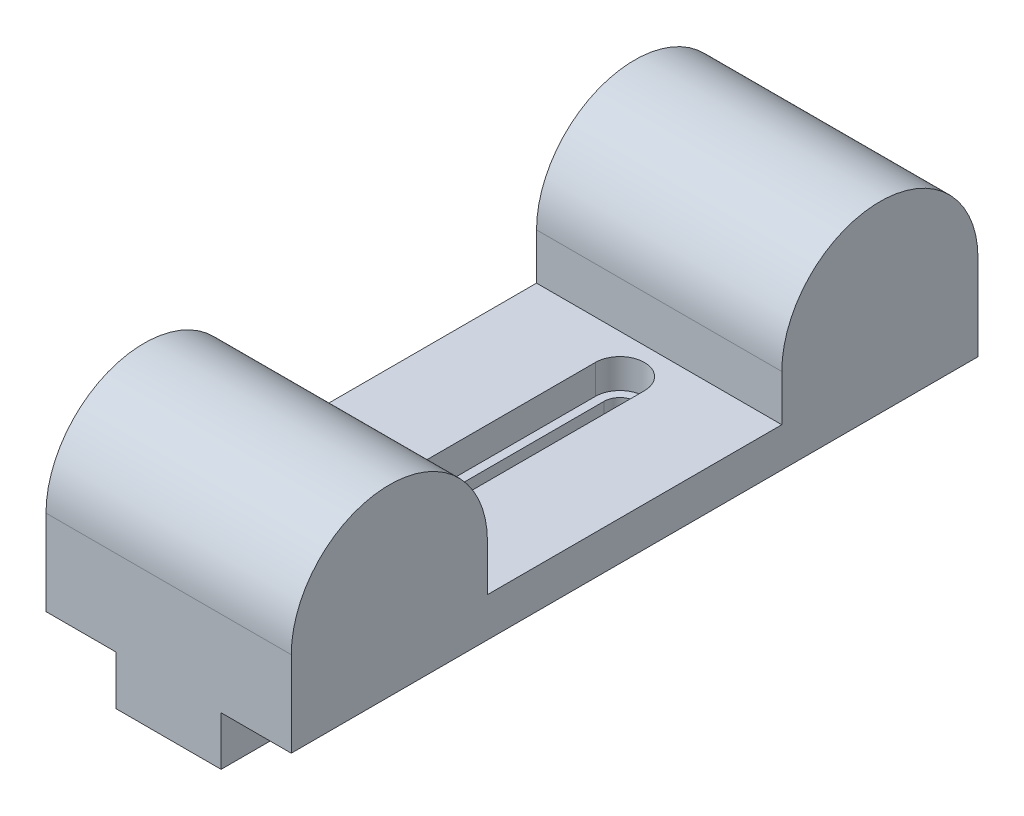
from build123d import *

# Parameters (mm, degrees)
BOSS_EXTRUDE1_DEPTH     = 12.5
SKETCH2_W               = 10.7
SKETCH2_H               = 41.65
BOSS_EXTRUDE2_DEPTH     = 5
CUT_EXTRUDE1_DEPTH      = 19.7
CUT_EXTRUDE1_DEPTH_BACK = 6
CUT_EXTRUDE2_START      = 4
CUT_EXTRUDE2_DEPTH      = 3


with BuildPart() as part:
    # Sketch1 → Boss-Extrude1 (new body, symmetric)
    with BuildSketch(Plane(origin=(0, 0, 0), x_dir=(0, 0, -1), z_dir=(1, 0, 0))):
        with BuildLine():
            Line((0, 0), (70, 0))
            Line((70, 0), (70, 8.7))
            ThreePointArc((70, 8.7), (60, 18.7), (50, 8.7))
            Line((50, 8.7), (50, 4))
            Line((50, 4), (20, 4))
            Line((20, 4), (20, 8.7))
            ThreePointArc((20, 8.7), (10, 18.7), (0, 8.7))
            Line((0, 8.7), (0, 0))
        make_face()
    extrude(amount=BOSS_EXTRUDE1_DEPTH, both=True)

    # Sketch2 → Boss-Extrude2 (add)
    with BuildSketch(Plane(origin=(0, 0, 0), x_dir=(1, 0, 0), z_dir=(0, 1, 0))):
        with BuildLine():
            ThreePointArc((-5.35, 41.65), (0, 47), (5.35, 41.65))
            Line((5.35, 41.65), (-5.35, 41.65))
        make_face()
        with Locations((0, 20.825)):
            Rectangle(SKETCH2_W, SKETCH2_H)
    extrude(amount=-BOSS_EXTRUDE2_DEPTH)

    # Sketch4 → Cut-Extrude1 (cut, two sides)
    with BuildSketch(Plane(origin=(0, 0, 0), x_dir=(1, 0, 0), z_dir=(0, 1, 0))) as cut_extrude1_sk:
        with BuildLine():
            Line((-1.625, 40), (1.625, 40))
            Line((1.625, 40), (1.625, 46))
            ThreePointArc((1.625, 46), (0, 47.625), (-1.625, 46))
            Line((-1.625, 46), (-1.625, 40))
        make_face()
        with BuildLine():
            Line((1.625, 38.100164481), (1.625, 40))
            ThreePointArc((1.625, 40), (0, 38.375), (-1.625, 40))
            Line((-1.625, 40), (-1.625, 38.100164481))
            ThreePointArc((-1.625, 38.100164481), (0, 37.5), (1.625, 38.100164481))
        make_face()
        with BuildLine():
            ThreePointArc((-1.625, 40), (0, 38.375), (1.625, 40))
            Line((1.625, 40), (-1.625, 40))
        make_face()
        with BuildLine():
            Line((1.625, 32.899835519), (1.625, 38.100164481))
            ThreePointArc((1.625, 38.100164481), (0, 37.5), (-1.625, 38.100164481))
            Line((-1.625, 38.100164481), (-1.625, 32.899835519))
            ThreePointArc((-1.625, 32.899835519), (0, 33.5), (1.625, 32.899835519))
        make_face()
        with BuildLine():
            ThreePointArc((-1.625, 31), (0, 32.625), (1.625, 31))
            Line((1.625, 31), (1.625, 32.899835519))
            ThreePointArc((1.625, 32.899835519), (0, 33.5), (-1.625, 32.899835519))
            Line((-1.625, 32.899835519), (-1.625, 31))
        make_face()
        with BuildLine():
            Line((-1.625, 31), (1.625, 31))
            ThreePointArc((1.625, 31), (0, 32.625), (-1.625, 31))
        make_face()
        with BuildLine():
            Line((1.625, 25), (1.625, 31))
            Line((1.625, 31), (-1.625, 31))
            Line((-1.625, 31), (-1.625, 25))
            ThreePointArc((-1.625, 25), (0, 23.375), (1.625, 25))
        make_face()
    extrude(amount=CUT_EXTRUDE1_DEPTH, mode=Mode.SUBTRACT)
    extrude(cut_extrude1_sk.sketch, amount=-CUT_EXTRUDE1_DEPTH_BACK, mode=Mode.SUBTRACT)

    # Sketch4_3 → Cut-Extrude2 (cut)
    with BuildSketch(Plane(origin=(0, 0, 0), x_dir=(1, 0, 0), z_dir=(0, 1, 0)).offset(CUT_EXTRUDE2_START)):
        with BuildLine():
            Line((2.5, 25), (2.5, 31))
            Line((2.5, 31), (1.625, 31))
            Line((1.625, 31), (1.625, 25))
            ThreePointArc((1.625, 25), (0, 23.375), (-1.625, 25))
            Line((-1.625, 25), (-1.625, 31))
            Line((-1.625, 31), (-2.5, 31))
            Line((-2.5, 31), (-2.5, 25))
            ThreePointArc((-2.5, 25), (0, 22.5), (2.5, 25))
        make_face()
        with BuildLine():
            ThreePointArc((-1.625, 32.899835519), (-2.270737766, 32.045825033), (-2.5, 31))
            Line((-2.5, 31), (-1.625, 31))
            Line((-1.625, 31), (-1.625, 32.899835519))
        make_face()
        with BuildLine():
            ThreePointArc((-1.625, 38.100164481), (-2.270737766, 38.954174967), (-2.5, 40))
            Line((-2.5, 40), (-2.5, 31))
            ThreePointArc((-2.5, 31), (-2.270737766, 32.045825033), (-1.625, 32.899835519))
            Line((-1.625, 32.899835519), (-1.625, 38.100164481))
        make_face()
        with BuildLine():
            Line((1.625, 31), (2.5, 31))
            ThreePointArc((2.5, 31), (2.270737766, 32.045825033), (1.625, 32.899835519))
            Line((1.625, 32.899835519), (1.625, 31))
        make_face()
        with BuildLine():
            Line((2.5, 31), (2.5, 40))
            ThreePointArc((2.5, 40), (2.270737766, 38.954174967), (1.625, 38.100164481))
            Line((1.625, 38.100164481), (1.625, 32.899835519))
            ThreePointArc((1.625, 32.899835519), (2.270737766, 32.045825033), (2.5, 31))
        make_face()
        with BuildLine():
            ThreePointArc((1.625, 38.100164481), (2.270737766, 38.954174967), (2.5, 40))
            Line((2.5, 40), (1.625, 40))
            Line((1.625, 40), (1.625, 38.100164481))
        make_face()
        with BuildLine():
            Line((2.5, 40), (2.5, 46))
            ThreePointArc((2.5, 46), (0, 48.5), (-2.5, 46))
            Line((-2.5, 46), (-2.5, 40))
            Line((-2.5, 40), (-1.625, 40))
            Line((-1.625, 40), (-1.625, 46))
            ThreePointArc((-1.625, 46), (0, 47.625), (1.625, 46))
            Line((1.625, 46), (1.625, 40))
            Line((1.625, 40), (2.5, 40))
        make_face()
        with BuildLine():
            Line((-1.625, 40), (-2.5, 40))
            ThreePointArc((-2.5, 40), (-2.270737766, 38.954174967), (-1.625, 38.100164481))
            Line((-1.625, 38.100164481), (-1.625, 40))
        make_face()
    extrude(amount=-CUT_EXTRUDE2_DEPTH, mode=Mode.SUBTRACT)


solid = part.part
